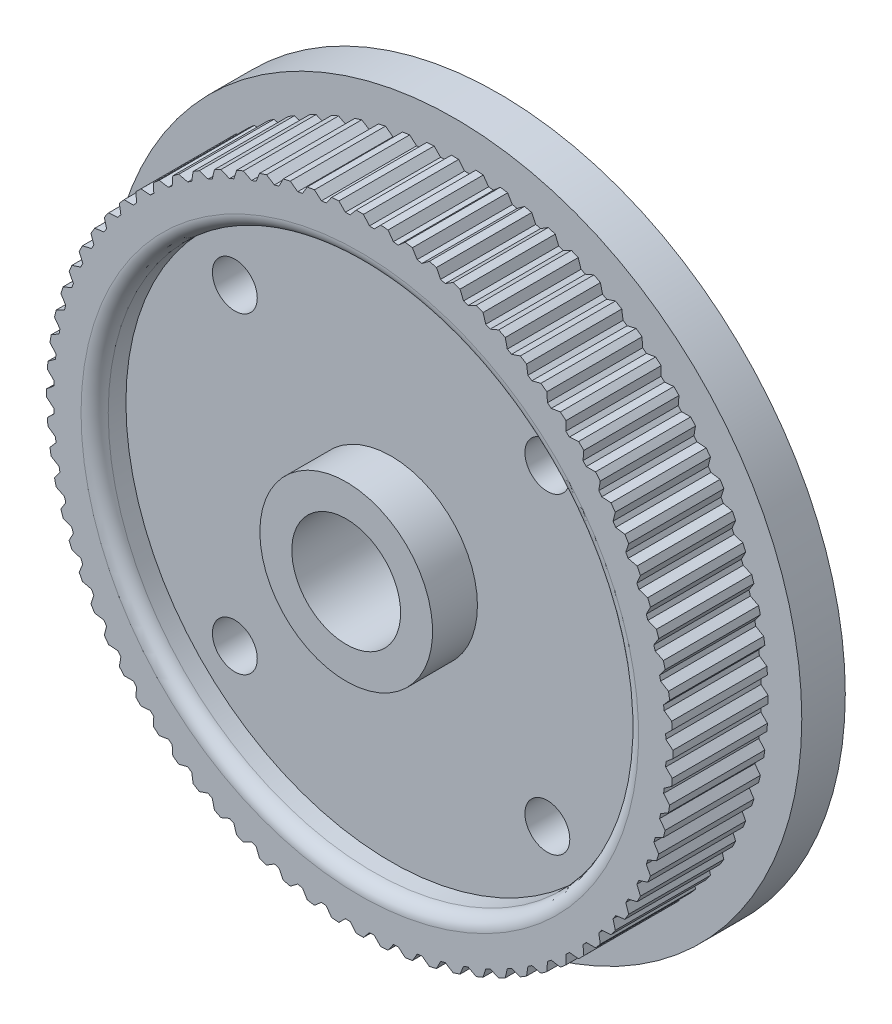
from build123d import *

# Parameters (mm, degrees)
SKETCH2_R               = 26.93387409
CUT_EXTRUDE1_DEPTH      = 7
SKETCH4_R               = 19.5
SKETCH4_R_2             = 6.35
CUT_EXTRUDE3_DEPTH      = 10
CUT_EXTRUDE3_DEPTH_BACK = 2.3
FILLET1_R               = 1
SKETCH5_R               = 19.5
SKETCH5_R_2             = 8.5
CUT_EXTRUDE4_DEPTH      = 4
SKETCH6_R               = 1.65
CUT_EXTRUDE5_DEPTH      = 8.2


with BuildPart() as part:
    # Sketch1 → Revolve1 (revolve)
    with BuildSketch(Plane(origin=(0, 0, 0), x_dir=(0, 0, -1), z_dir=(1, 0, 0))):
        Polygon((0, 4), (0, 8.5), (1, 8.5), (1, 23.025), (8, 23.025), (8, 25.5), (11.2, 25.5), (11.2, 8.5), (17.5, 8.5), (17.5, 4), align=None)
    revolve(axis=Axis((0, 0, 0), (0, 0, -1)))

    # Sketch2 → Cut-Extrude1 (cut)
    with BuildSketch(Plane.XY.offset(-1)):
        Circle(SKETCH2_R)
        with BuildLine():
            Line((0.27, 23.023416884), (0.705900047, 22.503931437))
            ThreePointArc((0.705900047, 22.503931437), (0.883934752, 22.497641751), (1.061914118, 22.489943606))
            Line((1.061914118, 22.489943606), (1.537228789, 22.973627329))
            ThreePointArc((1.537228789, 22.973627329), (1.671903473, 22.964219207), (1.806520679, 22.954021609))
            ThreePointArc((1.806520679, 22.954021609), (1.94107578, 22.943034887), (2.075564149, 22.931259417))
            Line((2.075564149, 22.931259417), (2.469362103, 22.379175047))
            ThreePointArc((2.469362103, 22.379175047), (2.646354504, 22.358936308), (2.82318123, 22.337297794))
            Line((2.82318123, 22.337297794), (3.334980052, 22.782197722))
            ThreePointArc((3.334980052, 22.782197722), (3.468501426, 22.762252148), (3.601903558, 22.741524042))
            ThreePointArc((3.601903558, 22.741524042), (3.735181862, 22.720014117), (3.868331756, 22.697723111))
            Line((3.868331756, 22.697723111), (4.217599721, 22.116443602))
            ThreePointArc((4.217599721, 22.116443602), (4.3924586, 22.082380588), (4.56704249, 22.046935113))
            Line((4.56704249, 22.046935113), (5.112170053, 22.450308291))
            ThreePointArc((5.112170053, 22.450308291), (5.243714913, 22.419948236), (5.375079503, 22.388817417))
            ThreePointArc((5.375079503, 22.388817417), (5.506259305, 22.356916904), (5.63724981, 22.324247794))
            Line((5.63724981, 22.324247794), (5.939834435, 21.717356927))
            ThreePointArc((5.939834435, 21.717356927), (6.111481729, 21.669679649), (6.282746415, 21.620645746))
            Line((6.282746415, 21.620645746), (6.857841826, 21.980005243))
            ThreePointArc((6.857841826, 21.980005243), (6.986599155, 21.939417888), (7.115116295, 21.898076288))
            ThreePointArc((7.115116295, 21.898076288), (7.243388829, 21.855981865), (7.371412345, 21.813136066))
            Line((7.371412345, 21.813136066), (7.625448094, 21.184375525))
            ThreePointArc((7.625448094, 21.184375525), (7.79282554, 21.123377928), (7.959715119, 21.061057909))
            Line((7.959715119, 21.061057909), (8.561232724, 21.374188154))
            ThreePointArc((8.561232724, 21.374188154), (8.68640869, 21.323623732), (8.81128603, 21.272326236))
            ThreePointArc((8.81128603, 21.272326236), (8.935860452, 21.220297429), (9.060127672, 21.167539101))
            Line((9.060127672, 21.167539101), (9.264048329, 20.520785403))
            ThreePointArc((9.264048329, 20.520785403), (9.426123991, 20.446843559), (9.587609532, 20.371621645))
            Line((9.587609532, 20.371621645), (10.211840775, 20.636592087))
            ThreePointArc((10.211840775, 20.636592087), (10.332663627, 20.576362346), (10.453131257, 20.515425219))
            ThreePointArc((10.453131257, 20.515425219), (10.573239523, 20.453782804), (10.692984298, 20.391437218))
            Line((10.692984298, 20.391437218), (10.845532626, 19.730677815))
            ThreePointArc((10.845532626, 19.730677815), (11.001307252, 19.644247599), (11.156393145, 19.55658756))
            Line((11.156393145, 19.55658756), (11.799489432, 19.771764568))
            ThreePointArc((11.799489432, 19.771764568), (11.915214256, 19.702240843), (12.030529453, 19.632039784))
            ThreePointArc((12.030529453, 19.632039784), (12.145431058, 19.561163805), (12.259915121, 19.489615343))
            Line((12.259915121, 19.489615343), (12.360150608, 18.818924038))
            ThreePointArc((12.360150608, 18.818924038), (12.508663796, 18.720538321), (12.656393883, 18.62098061))
            Line((12.656393883, 18.62098061), (13.314390313, 18.785037546))
            ThreePointArc((13.314390313, 18.785037546), (13.424303627, 18.706648474), (13.533755434, 18.627616295))
            ThreePointArc((13.533755434, 18.627616295), (13.642741971, 18.547943728), (13.75125949, 18.467633509))
            Line((13.75125949, 18.467633509), (13.798564151, 17.791145336))
            ThreePointArc((13.798564151, 17.791145336), (13.938900269, 17.681410699), (14.078363745, 17.570569122))
            Line((14.078363745, 17.570569122), (14.74720355, 17.68249452))
            ThreePointArc((14.74720355, 17.68249452), (14.850627703, 17.595723396), (14.953541313, 17.508347358))
            ThreePointArc((14.953541313, 17.508347358), (15.055940843, 17.420369409), (15.157822772, 17.331792574))
            Line((15.157822772, 17.331792574), (15.151904958, 16.653678307))
            ThreePointArc((15.151904958, 16.653678307), (15.283198786, 16.5332713), (15.413535813, 16.411829232))
            Line((15.413535813, 16.411829232), (16.089095374, 16.470933035))
            ThreePointArc((16.089095374, 16.470933035), (16.18539272, 16.376314833), (16.281133637, 16.281133637))
            ThreePointArc((16.281133637, 16.281133637), (16.376314833, 16.18539272), (16.470933035, 16.089095374))
            Line((16.470933035, 16.089095374), (16.411829232, 15.413535813))
            ThreePointArc((16.411829232, 15.413535813), (16.5332713, 15.283198786), (16.653678307, 15.151904958))
            Line((16.653678307, 15.151904958), (17.331792574, 15.157822772))
            ThreePointArc((17.331792574, 15.157822772), (17.420369409, 15.055940843), (17.508347358, 14.953541313))
            ThreePointArc((17.508347358, 14.953541313), (17.595723396, 14.850627703), (17.68249452, 14.74720355))
            Line((17.68249452, 14.74720355), (17.570569122, 14.078363745))
            ThreePointArc((17.570569122, 14.078363745), (17.681410699, 13.938900269), (17.791145336, 13.798564151))
            Line((17.791145336, 13.798564151), (18.467633509, 13.75125949))
            ThreePointArc((18.467633509, 13.75125949), (18.547943728, 13.642741971), (18.627616295, 13.533755434))
            ThreePointArc((18.627616295, 13.533755434), (18.706648474, 13.424303627), (18.785037546, 13.314390313))
            Line((18.785037546, 13.314390313), (18.62098061, 12.656393883))
            ThreePointArc((18.62098061, 12.656393883), (18.720538321, 12.508663796), (18.818924038, 12.360150608))
            Line((18.818924038, 12.360150608), (19.489615343, 12.259915121))
            ThreePointArc((19.489615343, 12.259915121), (19.561163805, 12.145431058), (19.632039784, 12.030529453))
            ThreePointArc((19.632039784, 12.030529453), (19.702240843, 11.915214256), (19.771764568, 11.799489432))
            Line((19.771764568, 11.799489432), (19.55658756, 11.156393145))
            ThreePointArc((19.55658756, 11.156393145), (19.644247599, 11.001307252), (19.730677815, 10.845532626))
            Line((19.730677815, 10.845532626), (20.391437218, 10.692984298))
            ThreePointArc((20.391437218, 10.692984298), (20.453782804, 10.573239523), (20.515425219, 10.453131257))
            ThreePointArc((20.515425219, 10.453131257), (20.576362346, 10.332663627), (20.636592087, 10.211840775))
            Line((20.636592087, 10.211840775), (20.371621645, 9.587609532))
            ThreePointArc((20.371621645, 9.587609532), (20.446843559, 9.426123991), (20.520785403, 9.264048329))
            Line((20.520785403, 9.264048329), (21.167539101, 9.060127672))
            ThreePointArc((21.167539101, 9.060127672), (21.220297429, 8.935860452), (21.272326236, 8.81128603))
            ThreePointArc((21.272326236, 8.81128603), (21.323623732, 8.68640869), (21.374188154, 8.561232724))
            Line((21.374188154, 8.561232724), (21.061057909, 7.959715119))
            ThreePointArc((21.061057909, 7.959715119), (21.123377928, 7.79282554), (21.184375525, 7.625448094))
            Line((21.184375525, 7.625448094), (21.813136066, 7.371412345))
            ThreePointArc((21.813136066, 7.371412345), (21.855981865, 7.243388829), (21.898076288, 7.115116295))
            ThreePointArc((21.898076288, 7.115116295), (21.939417888, 6.986599155), (21.980005243, 6.857841826))
            Line((21.980005243, 6.857841826), (21.620645746, 6.282746415))
            ThreePointArc((21.620645746, 6.282746415), (21.669679649, 6.111481729), (21.717356927, 5.939834435))
            Line((21.717356927, 5.939834435), (22.324247794, 5.63724981))
            ThreePointArc((22.324247794, 5.63724981), (22.356916904, 5.506259305), (22.388817417, 5.375079503))
            ThreePointArc((22.388817417, 5.375079503), (22.419948236, 5.243714913), (22.450308291, 5.112170053))
            Line((22.450308291, 5.112170053), (22.046935113, 4.56704249))
            ThreePointArc((22.046935113, 4.56704249), (22.082380588, 4.3924586), (22.116443602, 4.217599721))
            Line((22.116443602, 4.217599721), (22.697723111, 3.868331756))
            ThreePointArc((22.697723111, 3.868331756), (22.720014117, 3.735181862), (22.741524042, 3.601903558))
            ThreePointArc((22.741524042, 3.601903558), (22.762252148, 3.468501426), (22.782197722, 3.334980052))
            Line((22.782197722, 3.334980052), (22.337297794, 2.82318123))
            ThreePointArc((22.337297794, 2.82318123), (22.358936308, 2.646354504), (22.379175047, 2.469362103))
            Line((22.379175047, 2.469362103), (22.931259417, 2.075564149))
            ThreePointArc((22.931259417, 2.075564149), (22.943034887, 1.94107578), (22.954021609, 1.806520679))
            ThreePointArc((22.954021609, 1.806520679), (22.964219207, 1.671903473), (22.973627329, 1.537228789))
            Line((22.973627329, 1.537228789), (22.489943606, 1.061914118))
            ThreePointArc((22.489943606, 1.061914118), (22.497641751, 0.883934752), (22.503931437, 0.705900047))
            Line((22.503931437, 0.705900047), (23.023416884, 0.27))
            ThreePointArc((23.023416884, 0.27), (23.024604218, 0.135002321), (23.025, 0))
            ThreePointArc((23.025, 0), (23.024604218, -0.135002321), (23.023416884, -0.27))
            Line((23.023416884, -0.27), (22.503931437, -0.705900047))
            ThreePointArc((22.503931437, -0.705900047), (22.497641751, -0.883934752), (22.489943606, -1.061914118))
            Line((22.489943606, -1.061914118), (22.973627329, -1.537228789))
            ThreePointArc((22.973627329, -1.537228789), (22.964219207, -1.671903473), (22.954021609, -1.806520679))
            ThreePointArc((22.954021609, -1.806520679), (22.943034887, -1.94107578), (22.931259417, -2.075564149))
            Line((22.931259417, -2.075564149), (22.379175047, -2.469362103))
            ThreePointArc((22.379175047, -2.469362103), (22.358936308, -2.646354504), (22.337297794, -2.82318123))
            Line((22.337297794, -2.82318123), (22.782197722, -3.334980052))
            ThreePointArc((22.782197722, -3.334980052), (22.762252148, -3.468501426), (22.741524042, -3.601903558))
            ThreePointArc((22.741524042, -3.601903558), (22.720014117, -3.735181862), (22.697723111, -3.868331756))
            Line((22.697723111, -3.868331756), (22.116443602, -4.217599721))
            ThreePointArc((22.116443602, -4.217599721), (22.082380588, -4.3924586), (22.046935113, -4.56704249))
            Line((22.046935113, -4.56704249), (22.450308291, -5.112170053))
            ThreePointArc((22.450308291, -5.112170053), (22.419948236, -5.243714913), (22.388817417, -5.375079503))
            ThreePointArc((22.388817417, -5.375079503), (22.356916904, -5.506259305), (22.324247794, -5.63724981))
            Line((22.324247794, -5.63724981), (21.717356927, -5.939834435))
            ThreePointArc((21.717356927, -5.939834435), (21.669679649, -6.111481729), (21.620645746, -6.282746415))
            Line((21.620645746, -6.282746415), (21.980005243, -6.857841826))
            ThreePointArc((21.980005243, -6.857841826), (21.939417888, -6.986599155), (21.898076288, -7.115116295))
            ThreePointArc((21.898076288, -7.115116295), (21.855981865, -7.243388829), (21.813136066, -7.371412345))
            Line((21.813136066, -7.371412345), (21.184375525, -7.625448094))
            ThreePointArc((21.184375525, -7.625448094), (21.123377928, -7.79282554), (21.061057909, -7.959715119))
            Line((21.061057909, -7.959715119), (21.374188154, -8.561232724))
            ThreePointArc((21.374188154, -8.561232724), (21.323623732, -8.68640869), (21.272326236, -8.81128603))
            ThreePointArc((21.272326236, -8.81128603), (21.220297429, -8.935860452), (21.167539101, -9.060127672))
            Line((21.167539101, -9.060127672), (20.520785403, -9.264048329))
            ThreePointArc((20.520785403, -9.264048329), (20.446843559, -9.426123991), (20.371621645, -9.587609532))
            Line((20.371621645, -9.587609532), (20.636592087, -10.211840775))
            ThreePointArc((20.636592087, -10.211840775), (20.576362346, -10.332663627), (20.515425219, -10.453131257))
            ThreePointArc((20.515425219, -10.453131257), (20.453782804, -10.573239523), (20.391437218, -10.692984298))
            Line((20.391437218, -10.692984298), (19.730677815, -10.845532626))
            ThreePointArc((19.730677815, -10.845532626), (19.644247599, -11.001307252), (19.55658756, -11.156393145))
            Line((19.55658756, -11.156393145), (19.771764568, -11.799489432))
            ThreePointArc((19.771764568, -11.799489432), (19.702240843, -11.915214256), (19.632039784, -12.030529453))
            ThreePointArc((19.632039784, -12.030529453), (19.561163805, -12.145431058), (19.489615343, -12.259915121))
            Line((19.489615343, -12.259915121), (18.818924038, -12.360150608))
            ThreePointArc((18.818924038, -12.360150608), (18.720538321, -12.508663796), (18.62098061, -12.656393883))
            Line((18.62098061, -12.656393883), (18.785037546, -13.314390313))
            ThreePointArc((18.785037546, -13.314390313), (18.706648474, -13.424303627), (18.627616295, -13.533755434))
            ThreePointArc((18.627616295, -13.533755434), (18.547943728, -13.642741971), (18.467633509, -13.75125949))
            Line((18.467633509, -13.75125949), (17.791145336, -13.798564151))
            ThreePointArc((17.791145336, -13.798564151), (17.681410699, -13.938900269), (17.570569122, -14.078363745))
            Line((17.570569122, -14.078363745), (17.68249452, -14.74720355))
            ThreePointArc((17.68249452, -14.74720355), (17.595723396, -14.850627703), (17.508347358, -14.953541313))
            ThreePointArc((17.508347358, -14.953541313), (17.420369409, -15.055940843), (17.331792574, -15.157822772))
            Line((17.331792574, -15.157822772), (16.653678307, -15.151904958))
            ThreePointArc((16.653678307, -15.151904958), (16.5332713, -15.283198786), (16.411829232, -15.413535813))
            Line((16.411829232, -15.413535813), (16.470933035, -16.089095374))
            ThreePointArc((16.470933035, -16.089095374), (16.376314833, -16.18539272), (16.281133637, -16.281133637))
            ThreePointArc((16.281133637, -16.281133637), (16.18539272, -16.376314833), (16.089095374, -16.470933035))
            Line((16.089095374, -16.470933035), (15.413535813, -16.411829232))
            ThreePointArc((15.413535813, -16.411829232), (15.283198786, -16.5332713), (15.151904958, -16.653678307))
            Line((15.151904958, -16.653678307), (15.157822772, -17.331792574))
            ThreePointArc((15.157822772, -17.331792574), (15.055940843, -17.420369409), (14.953541313, -17.508347358))
            ThreePointArc((14.953541313, -17.508347358), (14.850627703, -17.595723396), (14.74720355, -17.68249452))
            Line((14.74720355, -17.68249452), (14.078363745, -17.570569122))
            ThreePointArc((14.078363745, -17.570569122), (13.938900269, -17.681410699), (13.798564151, -17.791145336))
            Line((13.798564151, -17.791145336), (13.75125949, -18.467633509))
            ThreePointArc((13.75125949, -18.467633509), (13.642741971, -18.547943728), (13.533755434, -18.627616295))
            ThreePointArc((13.533755434, -18.627616295), (13.424303627, -18.706648474), (13.314390313, -18.785037546))
            Line((13.314390313, -18.785037546), (12.656393883, -18.62098061))
            ThreePointArc((12.656393883, -18.62098061), (12.508663796, -18.720538321), (12.360150608, -18.818924038))
            Line((12.360150608, -18.818924038), (12.259915121, -19.489615343))
            ThreePointArc((12.259915121, -19.489615343), (12.145431058, -19.561163805), (12.030529453, -19.632039784))
            ThreePointArc((12.030529453, -19.632039784), (11.915214256, -19.702240843), (11.799489432, -19.771764568))
            Line((11.799489432, -19.771764568), (11.156393145, -19.55658756))
            ThreePointArc((11.156393145, -19.55658756), (11.001307252, -19.644247599), (10.845532626, -19.730677815))
            Line((10.845532626, -19.730677815), (10.692984298, -20.391437218))
            ThreePointArc((10.692984298, -20.391437218), (10.573239523, -20.453782804), (10.453131257, -20.515425219))
            ThreePointArc((10.453131257, -20.515425219), (10.332663627, -20.576362346), (10.211840775, -20.636592087))
            Line((10.211840775, -20.636592087), (9.587609532, -20.371621645))
            ThreePointArc((9.587609532, -20.371621645), (9.426123991, -20.446843559), (9.264048329, -20.520785403))
            Line((9.264048329, -20.520785403), (9.060127672, -21.167539101))
            ThreePointArc((9.060127672, -21.167539101), (8.935860452, -21.220297429), (8.81128603, -21.272326236))
            ThreePointArc((8.81128603, -21.272326236), (8.68640869, -21.323623732), (8.561232724, -21.374188154))
            Line((8.561232724, -21.374188154), (7.959715119, -21.061057909))
            ThreePointArc((7.959715119, -21.061057909), (7.79282554, -21.123377928), (7.625448094, -21.184375525))
            Line((7.625448094, -21.184375525), (7.371412345, -21.813136066))
            ThreePointArc((7.371412345, -21.813136066), (7.243388829, -21.855981865), (7.115116295, -21.898076288))
            ThreePointArc((7.115116295, -21.898076288), (6.986599155, -21.939417888), (6.857841826, -21.980005243))
            Line((6.857841826, -21.980005243), (6.282746415, -21.620645746))
            ThreePointArc((6.282746415, -21.620645746), (6.111481729, -21.669679649), (5.939834435, -21.717356927))
            Line((5.939834435, -21.717356927), (5.63724981, -22.324247794))
            ThreePointArc((5.63724981, -22.324247794), (5.506259305, -22.356916904), (5.375079503, -22.388817417))
            ThreePointArc((5.375079503, -22.388817417), (5.243714913, -22.419948236), (5.112170053, -22.450308291))
            Line((5.112170053, -22.450308291), (4.56704249, -22.046935113))
            ThreePointArc((4.56704249, -22.046935113), (4.3924586, -22.082380588), (4.217599721, -22.116443602))
            Line((4.217599721, -22.116443602), (3.868331756, -22.697723111))
            ThreePointArc((3.868331756, -22.697723111), (3.735181862, -22.720014117), (3.601903558, -22.741524042))
            ThreePointArc((3.601903558, -22.741524042), (3.468501426, -22.762252148), (3.334980052, -22.782197722))
            Line((3.334980052, -22.782197722), (2.82318123, -22.337297794))
            ThreePointArc((2.82318123, -22.337297794), (2.646354504, -22.358936308), (2.469362103, -22.379175047))
            Line((2.469362103, -22.379175047), (2.075564149, -22.931259417))
            ThreePointArc((2.075564149, -22.931259417), (1.94107578, -22.943034887), (1.806520679, -22.954021609))
            ThreePointArc((1.806520679, -22.954021609), (1.671903473, -22.964219207), (1.537228789, -22.973627329))
            Line((1.537228789, -22.973627329), (1.061914118, -22.489943606))
            ThreePointArc((1.061914118, -22.489943606), (0.883934752, -22.497641751), (0.705900047, -22.503931437))
            Line((0.705900047, -22.503931437), (0.27, -23.023416884))
            ThreePointArc((0.27, -23.023416884), (0.135002321, -23.024604218), (0, -23.025))
            ThreePointArc((0, -23.025), (-0.135002321, -23.024604218), (-0.27, -23.023416884))
            Line((-0.27, -23.023416884), (-0.705900047, -22.503931437))
            ThreePointArc((-0.705900047, -22.503931437), (-0.883934752, -22.497641751), (-1.061914118, -22.489943606))
            Line((-1.061914118, -22.489943606), (-1.537228789, -22.973627329))
            ThreePointArc((-1.537228789, -22.973627329), (-1.671903473, -22.964219207), (-1.806520679, -22.954021609))
            ThreePointArc((-1.806520679, -22.954021609), (-1.94107578, -22.943034887), (-2.075564149, -22.931259417))
            Line((-2.075564149, -22.931259417), (-2.469362103, -22.379175047))
            ThreePointArc((-2.469362103, -22.379175047), (-2.646354504, -22.358936308), (-2.82318123, -22.337297794))
            Line((-2.82318123, -22.337297794), (-3.334980052, -22.782197722))
            ThreePointArc((-3.334980052, -22.782197722), (-3.468501426, -22.762252148), (-3.601903558, -22.741524042))
            ThreePointArc((-3.601903558, -22.741524042), (-3.735181862, -22.720014117), (-3.868331756, -22.697723111))
            Line((-3.868331756, -22.697723111), (-4.217599721, -22.116443602))
            ThreePointArc((-4.217599721, -22.116443602), (-4.3924586, -22.082380588), (-4.56704249, -22.046935113))
            Line((-4.56704249, -22.046935113), (-5.112170053, -22.450308291))
            ThreePointArc((-5.112170053, -22.450308291), (-5.243714913, -22.419948236), (-5.375079503, -22.388817417))
            ThreePointArc((-5.375079503, -22.388817417), (-5.506259305, -22.356916904), (-5.63724981, -22.324247794))
            Line((-5.63724981, -22.324247794), (-5.939834435, -21.717356927))
            ThreePointArc((-5.939834435, -21.717356927), (-6.111481729, -21.669679649), (-6.282746415, -21.620645746))
            Line((-6.282746415, -21.620645746), (-6.857841826, -21.980005243))
            ThreePointArc((-6.857841826, -21.980005243), (-6.986599155, -21.939417888), (-7.115116295, -21.898076288))
            ThreePointArc((-7.115116295, -21.898076288), (-7.243388829, -21.855981865), (-7.371412345, -21.813136066))
            Line((-7.371412345, -21.813136066), (-7.625448094, -21.184375525))
            ThreePointArc((-7.625448094, -21.184375525), (-7.79282554, -21.123377928), (-7.959715119, -21.061057909))
            Line((-7.959715119, -21.061057909), (-8.561232724, -21.374188154))
            ThreePointArc((-8.561232724, -21.374188154), (-8.68640869, -21.323623732), (-8.81128603, -21.272326236))
            ThreePointArc((-8.81128603, -21.272326236), (-8.935860452, -21.220297429), (-9.060127672, -21.167539101))
            Line((-9.060127672, -21.167539101), (-9.264048329, -20.520785403))
            ThreePointArc((-9.264048329, -20.520785403), (-9.426123991, -20.446843559), (-9.587609532, -20.371621645))
            Line((-9.587609532, -20.371621645), (-10.211840775, -20.636592087))
            ThreePointArc((-10.211840775, -20.636592087), (-10.332663627, -20.576362346), (-10.453131257, -20.515425219))
            ThreePointArc((-10.453131257, -20.515425219), (-10.573239523, -20.453782804), (-10.692984298, -20.391437218))
            Line((-10.692984298, -20.391437218), (-10.845532626, -19.730677815))
            ThreePointArc((-10.845532626, -19.730677815), (-11.001307252, -19.644247599), (-11.156393145, -19.55658756))
            Line((-11.156393145, -19.55658756), (-11.799489432, -19.771764568))
            ThreePointArc((-11.799489432, -19.771764568), (-11.915214256, -19.702240843), (-12.030529453, -19.632039784))
            ThreePointArc((-12.030529453, -19.632039784), (-12.145431058, -19.561163805), (-12.259915121, -19.489615343))
            Line((-12.259915121, -19.489615343), (-12.360150608, -18.818924038))
            ThreePointArc((-12.360150608, -18.818924038), (-12.508663796, -18.720538321), (-12.656393883, -18.62098061))
            Line((-12.656393883, -18.62098061), (-13.314390313, -18.785037546))
            ThreePointArc((-13.314390313, -18.785037546), (-13.424303627, -18.706648474), (-13.533755434, -18.627616295))
            ThreePointArc((-13.533755434, -18.627616295), (-13.642741971, -18.547943728), (-13.75125949, -18.467633509))
            Line((-13.75125949, -18.467633509), (-13.798564151, -17.791145336))
            ThreePointArc((-13.798564151, -17.791145336), (-13.938900269, -17.681410699), (-14.078363745, -17.570569122))
            Line((-14.078363745, -17.570569122), (-14.74720355, -17.68249452))
            ThreePointArc((-14.74720355, -17.68249452), (-14.850627703, -17.595723396), (-14.953541313, -17.508347358))
            ThreePointArc((-14.953541313, -17.508347358), (-15.055940843, -17.420369409), (-15.157822772, -17.331792574))
            Line((-15.157822772, -17.331792574), (-15.151904958, -16.653678307))
            ThreePointArc((-15.151904958, -16.653678307), (-15.283198786, -16.5332713), (-15.413535813, -16.411829232))
            Line((-15.413535813, -16.411829232), (-16.089095374, -16.470933035))
            ThreePointArc((-16.089095374, -16.470933035), (-16.18539272, -16.376314833), (-16.281133637, -16.281133637))
            ThreePointArc((-16.281133637, -16.281133637), (-16.376314833, -16.18539272), (-16.470933035, -16.089095374))
            Line((-16.470933035, -16.089095374), (-16.411829232, -15.413535813))
            ThreePointArc((-16.411829232, -15.413535813), (-16.5332713, -15.283198786), (-16.653678307, -15.151904958))
            Line((-16.653678307, -15.151904958), (-17.331792574, -15.157822772))
            ThreePointArc((-17.331792574, -15.157822772), (-17.420369409, -15.055940843), (-17.508347358, -14.953541313))
            ThreePointArc((-17.508347358, -14.953541313), (-17.595723396, -14.850627703), (-17.68249452, -14.74720355))
            Line((-17.68249452, -14.74720355), (-17.570569122, -14.078363745))
            ThreePointArc((-17.570569122, -14.078363745), (-17.681410699, -13.938900269), (-17.791145336, -13.798564151))
            Line((-17.791145336, -13.798564151), (-18.467633509, -13.75125949))
            ThreePointArc((-18.467633509, -13.75125949), (-18.547943728, -13.642741971), (-18.627616295, -13.533755434))
            ThreePointArc((-18.627616295, -13.533755434), (-18.706648474, -13.424303627), (-18.785037546, -13.314390313))
            Line((-18.785037546, -13.314390313), (-18.62098061, -12.656393883))
            ThreePointArc((-18.62098061, -12.656393883), (-18.720538321, -12.508663796), (-18.818924038, -12.360150608))
            Line((-18.818924038, -12.360150608), (-19.489615343, -12.259915121))
            ThreePointArc((-19.489615343, -12.259915121), (-19.561163805, -12.145431058), (-19.632039784, -12.030529453))
            ThreePointArc((-19.632039784, -12.030529453), (-19.702240843, -11.915214256), (-19.771764568, -11.799489432))
            Line((-19.771764568, -11.799489432), (-19.55658756, -11.156393145))
            ThreePointArc((-19.55658756, -11.156393145), (-19.644247599, -11.001307252), (-19.730677815, -10.845532626))
            Line((-19.730677815, -10.845532626), (-20.391437218, -10.692984298))
            ThreePointArc((-20.391437218, -10.692984298), (-20.453782804, -10.573239523), (-20.515425219, -10.453131257))
            ThreePointArc((-20.515425219, -10.453131257), (-20.576362346, -10.332663627), (-20.636592087, -10.211840775))
            Line((-20.636592087, -10.211840775), (-20.371621645, -9.587609532))
            ThreePointArc((-20.371621645, -9.587609532), (-20.446843559, -9.426123991), (-20.520785403, -9.264048329))
            Line((-20.520785403, -9.264048329), (-21.167539101, -9.060127672))
            ThreePointArc((-21.167539101, -9.060127672), (-21.220297429, -8.935860452), (-21.272326236, -8.81128603))
            ThreePointArc((-21.272326236, -8.81128603), (-21.323623732, -8.68640869), (-21.374188154, -8.561232724))
            Line((-21.374188154, -8.561232724), (-21.061057909, -7.959715119))
            ThreePointArc((-21.061057909, -7.959715119), (-21.123377928, -7.79282554), (-21.184375525, -7.625448094))
            Line((-21.184375525, -7.625448094), (-21.813136066, -7.371412345))
            ThreePointArc((-21.813136066, -7.371412345), (-21.855981865, -7.243388829), (-21.898076288, -7.115116295))
            ThreePointArc((-21.898076288, -7.115116295), (-21.939417888, -6.986599155), (-21.980005243, -6.857841826))
            Line((-21.980005243, -6.857841826), (-21.620645746, -6.282746415))
            ThreePointArc((-21.620645746, -6.282746415), (-21.669679649, -6.111481729), (-21.717356927, -5.939834435))
            Line((-21.717356927, -5.939834435), (-22.324247794, -5.63724981))
            ThreePointArc((-22.324247794, -5.63724981), (-22.356916904, -5.506259305), (-22.388817417, -5.375079503))
            ThreePointArc((-22.388817417, -5.375079503), (-22.419948236, -5.243714913), (-22.450308291, -5.112170053))
            Line((-22.450308291, -5.112170053), (-22.046935113, -4.56704249))
            ThreePointArc((-22.046935113, -4.56704249), (-22.082380588, -4.3924586), (-22.116443602, -4.217599721))
            Line((-22.116443602, -4.217599721), (-22.697723111, -3.868331756))
            ThreePointArc((-22.697723111, -3.868331756), (-22.720014117, -3.735181862), (-22.741524042, -3.601903558))
            ThreePointArc((-22.741524042, -3.601903558), (-22.762252148, -3.468501426), (-22.782197722, -3.334980052))
            Line((-22.782197722, -3.334980052), (-22.337297794, -2.82318123))
            ThreePointArc((-22.337297794, -2.82318123), (-22.358936308, -2.646354504), (-22.379175047, -2.469362103))
            Line((-22.379175047, -2.469362103), (-22.931259417, -2.075564149))
            ThreePointArc((-22.931259417, -2.075564149), (-22.943034887, -1.94107578), (-22.954021609, -1.806520679))
            ThreePointArc((-22.954021609, -1.806520679), (-22.964219207, -1.671903473), (-22.973627329, -1.537228789))
            Line((-22.973627329, -1.537228789), (-22.489943606, -1.061914118))
            ThreePointArc((-22.489943606, -1.061914118), (-22.497641751, -0.883934752), (-22.503931437, -0.705900047))
            Line((-22.503931437, -0.705900047), (-23.023416884, -0.27))
            ThreePointArc((-23.023416884, -0.27), (-23.024604218, -0.135002321), (-23.025, 0))
            ThreePointArc((-23.025, 0), (-23.024604218, 0.135002321), (-23.023416884, 0.27))
            Line((-23.023416884, 0.27), (-22.503931437, 0.705900047))
            ThreePointArc((-22.503931437, 0.705900047), (-22.497641751, 0.883934752), (-22.489943606, 1.061914118))
            Line((-22.489943606, 1.061914118), (-22.973627329, 1.537228789))
            ThreePointArc((-22.973627329, 1.537228789), (-22.964219207, 1.671903473), (-22.954021609, 1.806520679))
            ThreePointArc((-22.954021609, 1.806520679), (-22.943034887, 1.94107578), (-22.931259417, 2.075564149))
            Line((-22.931259417, 2.075564149), (-22.379175047, 2.469362103))
            ThreePointArc((-22.379175047, 2.469362103), (-22.358936308, 2.646354504), (-22.337297794, 2.82318123))
            Line((-22.337297794, 2.82318123), (-22.782197722, 3.334980052))
            ThreePointArc((-22.782197722, 3.334980052), (-22.762252148, 3.468501426), (-22.741524042, 3.601903558))
            ThreePointArc((-22.741524042, 3.601903558), (-22.720014117, 3.735181862), (-22.697723111, 3.868331756))
            Line((-22.697723111, 3.868331756), (-22.116443602, 4.217599721))
            ThreePointArc((-22.116443602, 4.217599721), (-22.082380588, 4.3924586), (-22.046935113, 4.56704249))
            Line((-22.046935113, 4.56704249), (-22.450308291, 5.112170053))
            ThreePointArc((-22.450308291, 5.112170053), (-22.419948236, 5.243714913), (-22.388817417, 5.375079503))
            ThreePointArc((-22.388817417, 5.375079503), (-22.356916904, 5.506259305), (-22.324247794, 5.63724981))
            Line((-22.324247794, 5.63724981), (-21.717356927, 5.939834435))
            ThreePointArc((-21.717356927, 5.939834435), (-21.669679649, 6.111481729), (-21.620645746, 6.282746415))
            Line((-21.620645746, 6.282746415), (-21.980005243, 6.857841826))
            ThreePointArc((-21.980005243, 6.857841826), (-21.939417888, 6.986599155), (-21.898076288, 7.115116295))
            ThreePointArc((-21.898076288, 7.115116295), (-21.855981865, 7.243388829), (-21.813136066, 7.371412345))
            Line((-21.813136066, 7.371412345), (-21.184375525, 7.625448094))
            ThreePointArc((-21.184375525, 7.625448094), (-21.123377928, 7.79282554), (-21.061057909, 7.959715119))
            Line((-21.061057909, 7.959715119), (-21.374188154, 8.561232724))
            ThreePointArc((-21.374188154, 8.561232724), (-21.323623732, 8.68640869), (-21.272326236, 8.81128603))
            ThreePointArc((-21.272326236, 8.81128603), (-21.220297429, 8.935860452), (-21.167539101, 9.060127672))
            Line((-21.167539101, 9.060127672), (-20.520785403, 9.264048329))
            ThreePointArc((-20.520785403, 9.264048329), (-20.446843559, 9.426123991), (-20.371621645, 9.587609532))
            Line((-20.371621645, 9.587609532), (-20.636592087, 10.211840775))
            ThreePointArc((-20.636592087, 10.211840775), (-20.576362346, 10.332663627), (-20.515425219, 10.453131257))
            ThreePointArc((-20.515425219, 10.453131257), (-20.453782804, 10.573239523), (-20.391437218, 10.692984298))
            Line((-20.391437218, 10.692984298), (-19.730677815, 10.845532626))
            ThreePointArc((-19.730677815, 10.845532626), (-19.644247599, 11.001307252), (-19.55658756, 11.156393145))
            Line((-19.55658756, 11.156393145), (-19.771764568, 11.799489432))
            ThreePointArc((-19.771764568, 11.799489432), (-19.702240843, 11.915214256), (-19.632039784, 12.030529453))
            ThreePointArc((-19.632039784, 12.030529453), (-19.561163805, 12.145431058), (-19.489615343, 12.259915121))
            Line((-19.489615343, 12.259915121), (-18.818924038, 12.360150608))
            ThreePointArc((-18.818924038, 12.360150608), (-18.720538321, 12.508663796), (-18.62098061, 12.656393883))
            Line((-18.62098061, 12.656393883), (-18.785037546, 13.314390313))
            ThreePointArc((-18.785037546, 13.314390313), (-18.706648474, 13.424303627), (-18.627616295, 13.533755434))
            ThreePointArc((-18.627616295, 13.533755434), (-18.547943728, 13.642741971), (-18.467633509, 13.75125949))
            Line((-18.467633509, 13.75125949), (-17.791145336, 13.798564151))
            ThreePointArc((-17.791145336, 13.798564151), (-17.681410699, 13.938900269), (-17.570569122, 14.078363745))
            Line((-17.570569122, 14.078363745), (-17.68249452, 14.74720355))
            ThreePointArc((-17.68249452, 14.74720355), (-17.595723396, 14.850627703), (-17.508347358, 14.953541313))
            ThreePointArc((-17.508347358, 14.953541313), (-17.420369409, 15.055940843), (-17.331792574, 15.157822772))
            Line((-17.331792574, 15.157822772), (-16.653678307, 15.151904958))
            ThreePointArc((-16.653678307, 15.151904958), (-16.5332713, 15.283198786), (-16.411829232, 15.413535813))
            Line((-16.411829232, 15.413535813), (-16.470933035, 16.089095374))
            ThreePointArc((-16.470933035, 16.089095374), (-16.376314833, 16.18539272), (-16.281133637, 16.281133637))
            ThreePointArc((-16.281133637, 16.281133637), (-16.18539272, 16.376314833), (-16.089095374, 16.470933035))
            Line((-16.089095374, 16.470933035), (-15.413535813, 16.411829232))
            ThreePointArc((-15.413535813, 16.411829232), (-15.283198786, 16.5332713), (-15.151904958, 16.653678307))
            Line((-15.151904958, 16.653678307), (-15.157822772, 17.331792574))
            ThreePointArc((-15.157822772, 17.331792574), (-15.055940843, 17.420369409), (-14.953541313, 17.508347358))
            ThreePointArc((-14.953541313, 17.508347358), (-14.850627703, 17.595723396), (-14.74720355, 17.68249452))
            Line((-14.74720355, 17.68249452), (-14.078363745, 17.570569122))
            ThreePointArc((-14.078363745, 17.570569122), (-13.938900269, 17.681410699), (-13.798564151, 17.791145336))
            Line((-13.798564151, 17.791145336), (-13.75125949, 18.467633509))
            ThreePointArc((-13.75125949, 18.467633509), (-13.642741971, 18.547943728), (-13.533755434, 18.627616295))
            ThreePointArc((-13.533755434, 18.627616295), (-13.424303627, 18.706648474), (-13.314390313, 18.785037546))
            Line((-13.314390313, 18.785037546), (-12.656393883, 18.62098061))
            ThreePointArc((-12.656393883, 18.62098061), (-12.508663796, 18.720538321), (-12.360150608, 18.818924038))
            Line((-12.360150608, 18.818924038), (-12.259915121, 19.489615343))
            ThreePointArc((-12.259915121, 19.489615343), (-12.145431058, 19.561163805), (-12.030529453, 19.632039784))
            ThreePointArc((-12.030529453, 19.632039784), (-11.915214256, 19.702240843), (-11.799489432, 19.771764568))
            Line((-11.799489432, 19.771764568), (-11.156393145, 19.55658756))
            ThreePointArc((-11.156393145, 19.55658756), (-11.001307252, 19.644247599), (-10.845532626, 19.730677815))
            Line((-10.845532626, 19.730677815), (-10.692984298, 20.391437218))
            ThreePointArc((-10.692984298, 20.391437218), (-10.573239523, 20.453782804), (-10.453131257, 20.515425219))
            ThreePointArc((-10.453131257, 20.515425219), (-10.332663627, 20.576362346), (-10.211840775, 20.636592087))
            Line((-10.211840775, 20.636592087), (-9.587609532, 20.371621645))
            ThreePointArc((-9.587609532, 20.371621645), (-9.426123991, 20.446843559), (-9.264048329, 20.520785403))
            Line((-9.264048329, 20.520785403), (-9.060127672, 21.167539101))
            ThreePointArc((-9.060127672, 21.167539101), (-8.935860452, 21.220297429), (-8.81128603, 21.272326236))
            ThreePointArc((-8.81128603, 21.272326236), (-8.68640869, 21.323623732), (-8.561232724, 21.374188154))
            Line((-8.561232724, 21.374188154), (-7.959715119, 21.061057909))
            ThreePointArc((-7.959715119, 21.061057909), (-7.79282554, 21.123377928), (-7.625448094, 21.184375525))
            Line((-7.625448094, 21.184375525), (-7.371412345, 21.813136066))
            ThreePointArc((-7.371412345, 21.813136066), (-7.243388829, 21.855981865), (-7.115116295, 21.898076288))
            ThreePointArc((-7.115116295, 21.898076288), (-6.986599155, 21.939417888), (-6.857841826, 21.980005243))
            Line((-6.857841826, 21.980005243), (-6.282746415, 21.620645746))
            ThreePointArc((-6.282746415, 21.620645746), (-6.111481729, 21.669679649), (-5.939834435, 21.717356927))
            Line((-5.939834435, 21.717356927), (-5.63724981, 22.324247794))
            ThreePointArc((-5.63724981, 22.324247794), (-5.506259305, 22.356916904), (-5.375079503, 22.388817417))
            ThreePointArc((-5.375079503, 22.388817417), (-5.243714913, 22.419948236), (-5.112170053, 22.450308291))
            Line((-5.112170053, 22.450308291), (-4.56704249, 22.046935113))
            ThreePointArc((-4.56704249, 22.046935113), (-4.3924586, 22.082380588), (-4.217599721, 22.116443602))
            Line((-4.217599721, 22.116443602), (-3.868331756, 22.697723111))
            ThreePointArc((-3.868331756, 22.697723111), (-3.735181862, 22.720014117), (-3.601903558, 22.741524042))
            ThreePointArc((-3.601903558, 22.741524042), (-3.468501426, 22.762252148), (-3.334980052, 22.782197722))
            Line((-3.334980052, 22.782197722), (-2.82318123, 22.337297794))
            ThreePointArc((-2.82318123, 22.337297794), (-2.646354504, 22.358936308), (-2.469362103, 22.379175047))
            Line((-2.469362103, 22.379175047), (-2.075564149, 22.931259417))
            ThreePointArc((-2.075564149, 22.931259417), (-1.94107578, 22.943034887), (-1.806520679, 22.954021609))
            ThreePointArc((-1.806520679, 22.954021609), (-1.671903473, 22.964219207), (-1.537228789, 22.973627329))
            Line((-1.537228789, 22.973627329), (-1.061914118, 22.489943606))
            ThreePointArc((-1.061914118, 22.489943606), (-0.883934752, 22.497641751), (-0.705900047, 22.503931437))
            Line((-0.705900047, 22.503931437), (-0.27, 23.023416884))
            ThreePointArc((-0.27, 23.023416884), (-0.135002321, 23.024604218), (0, 23.025))
            ThreePointArc((0, 23.025), (0.135002321, 23.024604218), (0.27, 23.023416884))
        make_face(mode=Mode.SUBTRACT)
    extrude(amount=-CUT_EXTRUDE1_DEPTH, mode=Mode.SUBTRACT)

    # Sketch4 → Cut-Extrude3 (cut, two sides)
    with BuildSketch(Plane.XY.offset(-1)) as cut_extrude3_sk:
        Circle(SKETCH4_R)
        Circle(SKETCH4_R_2, mode=Mode.SUBTRACT)
    extrude(amount=CUT_EXTRUDE3_DEPTH, mode=Mode.SUBTRACT)
    extrude(cut_extrude3_sk.sketch, amount=-CUT_EXTRUDE3_DEPTH_BACK, mode=Mode.SUBTRACT)

    # Fillet1
    fillet1_edges = [part.edges().sort_by_distance(p)[0] for p in [
        (-19.5, 0, -1),
    ]]
    fillet(fillet1_edges, radius=FILLET1_R)

    # Sketch5 → Cut-Extrude4 (cut)
    with BuildSketch(Plane(origin=(0, 0, -11.2), x_dir=(-1, 0, 0), z_dir=(0, 0, -1))):
        Circle(SKETCH5_R)
        Circle(SKETCH5_R_2, mode=Mode.SUBTRACT)
    extrude(amount=-CUT_EXTRUDE4_DEPTH, mode=Mode.SUBTRACT)

    # Sketch6 → Cut-Extrude5 (cut, through all)
    with BuildSketch(Plane(origin=(0, 0, -7.2), x_dir=(-1, 0, 0), z_dir=(0, 0, -1))):
        with Locations((-11.490485194, 11.490485194)):
            Circle(SKETCH6_R)
        with Locations((11.490485194, 11.490485194)):
            Circle(SKETCH6_R)
        with Locations((11.490485194, -11.490485194)):
            Circle(SKETCH6_R)
        with Locations((-11.490485194, -11.490485194)):
            Circle(SKETCH6_R)
    extrude(amount=-CUT_EXTRUDE5_DEPTH, mode=Mode.SUBTRACT)


solid = part.part
